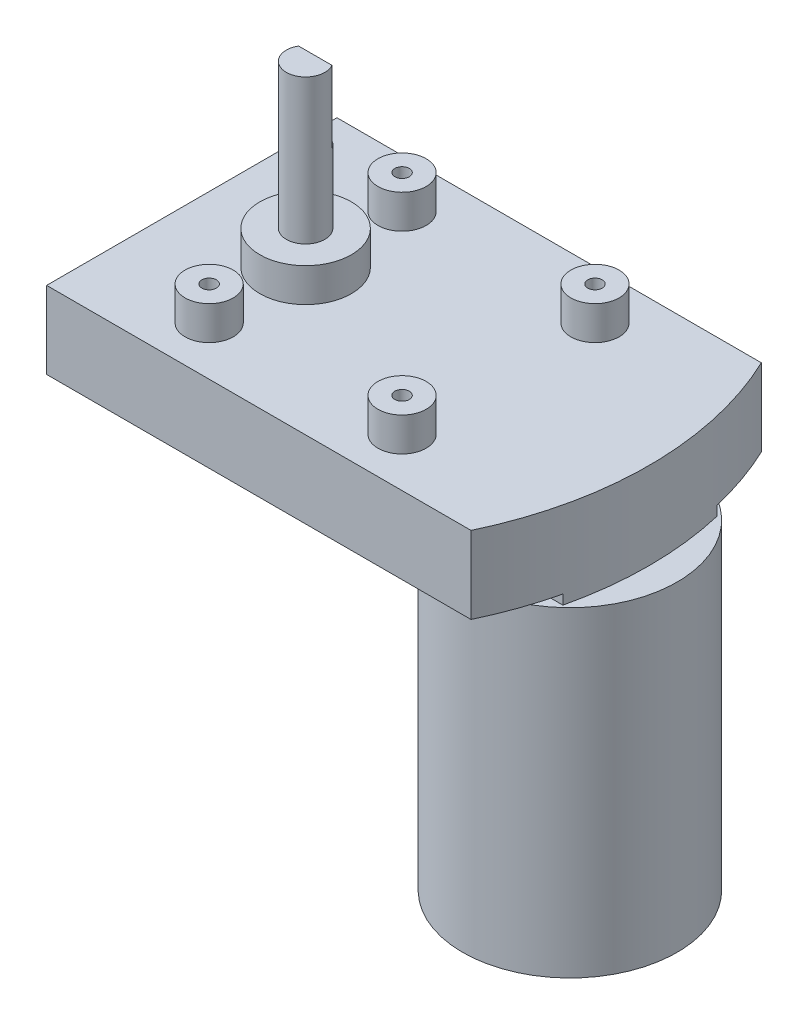
from build123d import *

# Parameters (mm, degrees)
SKETCH_1_W          = 88
SKETCH_1_H          = 60.2
EXTRUDE_1_DEPTH     = 16
SKETCH_1_4_R        = 5
SKETCH_1_4_R_2      = 9.5
EXTRUDE_3_DEPTH     = 23
SKETCH_2_R          = 4
EXTRUDE_4_DEPTH     = 30
CUT_EXTRUDE_3_DEPTH = 15
SKETCH_4_R          = 1.5
CUT_EXTRUDE_4_DEPTH = 10
EXTRUDE_6_DEPTH     = 16
EXTRUDE_7_DEPTH     = 2
SKETCH_7_R          = 22.25
EXTRUDE_8_DEPTH     = 66.5


with BuildPart() as part:
    # 草图1 → 凸台-拉伸1 (new body)
    with BuildSketch(Plane(origin=(0, 0, 0), x_dir=(1, 0, 0), z_dir=(0, 1, 0))):
        Rectangle(SKETCH_1_W, SKETCH_1_H)
    extrude(amount=EXTRUDE_1_DEPTH)

    # 草图1<4> → 凸台-拉伸3 (add)
    with BuildSketch(Plane(origin=(0, 0, 0), x_dir=(1, 0, 0), z_dir=(0, 1, 0))):
        with Locations((-20.4, 20)):
            Circle(SKETCH_1_4_R)
        with Locations((19.6, 20)):
            Circle(SKETCH_1_4_R)
        with Locations((19.6, -20)):
            Circle(SKETCH_1_4_R)
        with Locations((-20.4, -20)):
            Circle(SKETCH_1_4_R)
        with Locations((-20.4, 0)):
            Circle(SKETCH_1_4_R_2)
    extrude(amount=EXTRUDE_3_DEPTH)

    # 草图2 → 凸台-拉伸4 (add)
    with BuildSketch(Plane(origin=(0, 23, 0), x_dir=(1, 0, 0), z_dir=(0, 1, 0))):
        with Locations((-20.4, 0)):
            Circle(SKETCH_2_R)
    extrude(amount=EXTRUDE_4_DEPTH)

    # 草图3 → 切除-拉伸3 (cut)
    with BuildSketch(Plane(origin=(0, 53, 0), x_dir=(1, 0, 0), z_dir=(0, 1, 0))):
        with BuildLine():
            Line((-23.864101615, 2), (-16.935898385, 2))
            ThreePointArc((-16.935898385, 2), (-20.4, 4), (-23.864101615, 2))
        make_face()
    extrude(amount=-CUT_EXTRUDE_3_DEPTH, mode=Mode.SUBTRACT)

    # 草图4 → 切除-拉伸4 (cut)
    with BuildSketch(Plane(origin=(0, 23, 0), x_dir=(1, 0, 0), z_dir=(0, 1, 0))):
        with Locations((-20.4, 20)):
            Circle(SKETCH_4_R)
        with Locations((19.6, 20)):
            Circle(SKETCH_4_R)
        with Locations((19.6, -20)):
            Circle(SKETCH_4_R)
        with Locations((-20.4, -20)):
            Circle(SKETCH_4_R)
    extrude(amount=-CUT_EXTRUDE_4_DEPTH, mode=Mode.SUBTRACT)

    # 草图5 → 凸台-拉伸6 (add)
    with BuildSketch(Plane(origin=(0, 0, 0), x_dir=(1, 0, 0), z_dir=(0, 1, 0))):
        with BuildLine():
            Line((44, -30.1), (44, 30.1))
            ThreePointArc((44, 30.1), (50.801977879, 0), (44, -30.1))
        make_face()
    extrude(amount=EXTRUDE_6_DEPTH)

    # 草图6 → 凸台-拉伸7 (add)
    with BuildSketch(Plane.XZ):
        with BuildLine():
            Line((18, -16), (48.948878029, -16))
            ThreePointArc((48.948878029, -16), (50.801977879, 0), (48.948878029, 16))
            Line((48.948878029, 16), (18, 16))
            Line((18, 16), (18, -16))
        make_face()
    extrude(amount=EXTRUDE_7_DEPTH)

    # 草图7 → 凸台-拉伸8 (add)
    with BuildSketch(Plane.XZ.offset(2)):
        with Locations((34.40098894, 0)):
            Circle(SKETCH_7_R)
    extrude(amount=EXTRUDE_8_DEPTH)


solid = part.part
